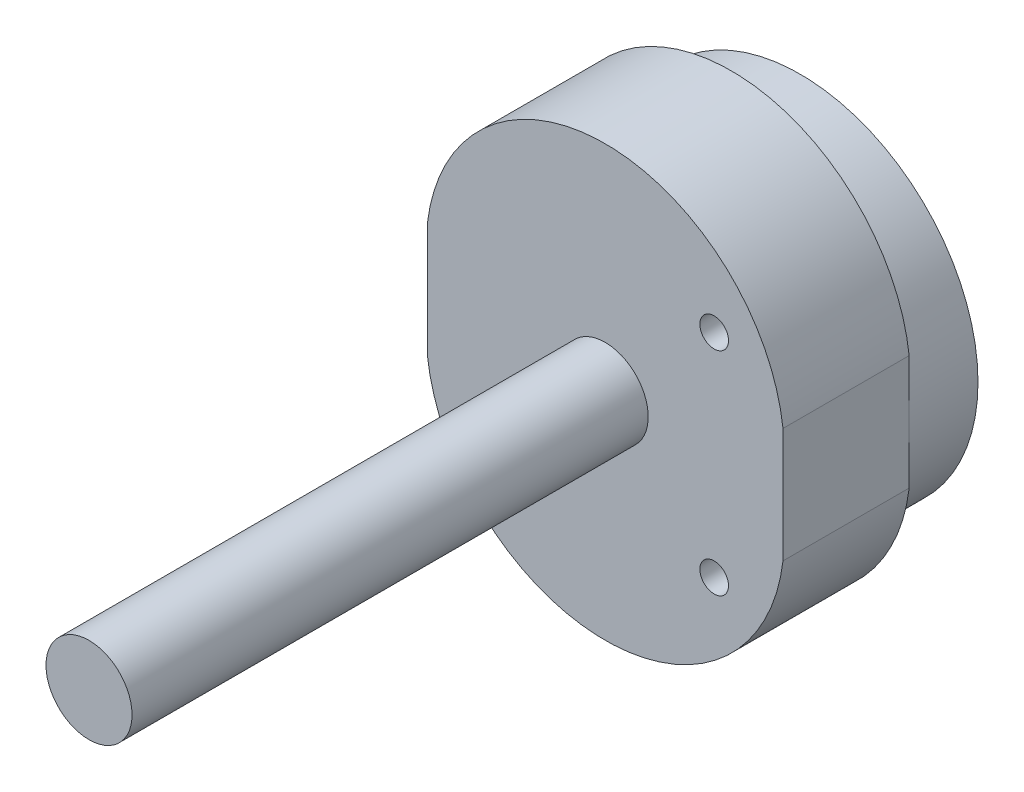
from build123d import *

# Parameters (mm, degrees)
BOSS_EXTRUDE1_DEPTH = 22
SKETCH2_R           = 31
BOSS_EXTRUDE2_DEPTH = 12
SKETCH3_R           = 2.5
CUT_EXTRUDE2_DEPTH  = 12
SKETCH4_R           = 7.5
BOSS_EXTRUDE3_DEPTH = 90


with BuildPart() as part:
    # Sketch1 → Boss-Extrude1 (new body)
    with BuildSketch(Plane.XY):
        with BuildLine():
            Line((-31, -10), (-31, 10))
            ThreePointArc((-31, 10), (0, 37.5), (31, 10))
            Line((31, 10), (31, -10))
            ThreePointArc((31, -10), (0, -37.5), (-31, -10))
        make_face()
    extrude(amount=BOSS_EXTRUDE1_DEPTH)

    # Sketch2 → Boss-Extrude2 (add)
    with BuildSketch(Plane(origin=(0, 0, 0), x_dir=(-1, 0, 0), z_dir=(0, 0, -1))):
        Circle(SKETCH2_R)
    extrude(amount=BOSS_EXTRUDE2_DEPTH)

    # Sketch3 → Cut-Extrude2 (cut)
    with BuildSketch(Plane.XY.offset(22)):
        with Locations((19, 18.5)):
            Circle(SKETCH3_R)
        with Locations((19, -18.5)):
            Circle(SKETCH3_R)
    extrude(amount=-CUT_EXTRUDE2_DEPTH, mode=Mode.SUBTRACT)

    # Sketch4 → Boss-Extrude3 (add)
    with BuildSketch(Plane.XY.offset(22)):
        with Locations(Location((0, 0, 0), (0, 0, 180))):  # turned: the seam where the file's is
            Circle(SKETCH4_R)
    extrude(amount=BOSS_EXTRUDE3_DEPTH)


solid = part.part
